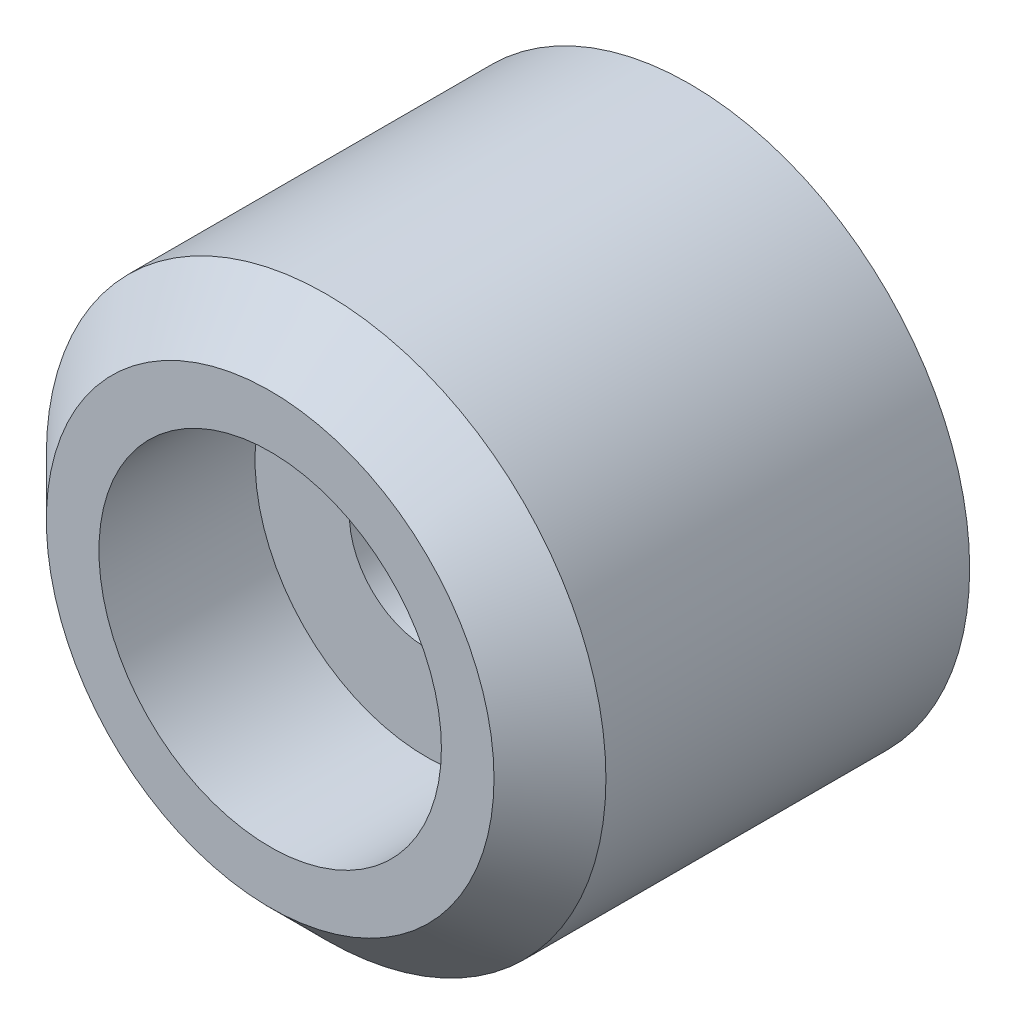
from build123d import *

# Parameters (mm, degrees)
SKETCH1_R                               = 10
BOSS_EXTRUDE1_DEPTH                     = 15
CHAMFER1_SIZE                           = 2
CBORE_FOR_M5_HEX_HEAD_BOLT1_D           = 5.5
CBORE_FOR_M5_HEX_HEAD_BOLT1_CBORE_D     = 12.24
CBORE_FOR_M5_HEX_HEAD_BOLT1_CBORE_DEPTH = 5.58


with BuildPart() as part:
    # Sketch1 → Boss-Extrude1 (new body)
    with BuildSketch(Plane.XY):
        Circle(SKETCH1_R)
    extrude(amount=BOSS_EXTRUDE1_DEPTH)

    # Chamfer1
    chamfer1_edges = [part.edges().sort_by_distance(p)[0] for p in [
        (-10, 0, 15),
    ]]
    chamfer(chamfer1_edges, length=CHAMFER1_SIZE)

    # CBORE for M5 Hex Head Bolt1 (through all)
    with Locations(Plane.XY.offset(15)):
        with Locations((0, 0)):
            CounterBoreHole(CBORE_FOR_M5_HEX_HEAD_BOLT1_D / 2, CBORE_FOR_M5_HEX_HEAD_BOLT1_CBORE_D / 2, CBORE_FOR_M5_HEX_HEAD_BOLT1_CBORE_DEPTH)


solid = part.part
